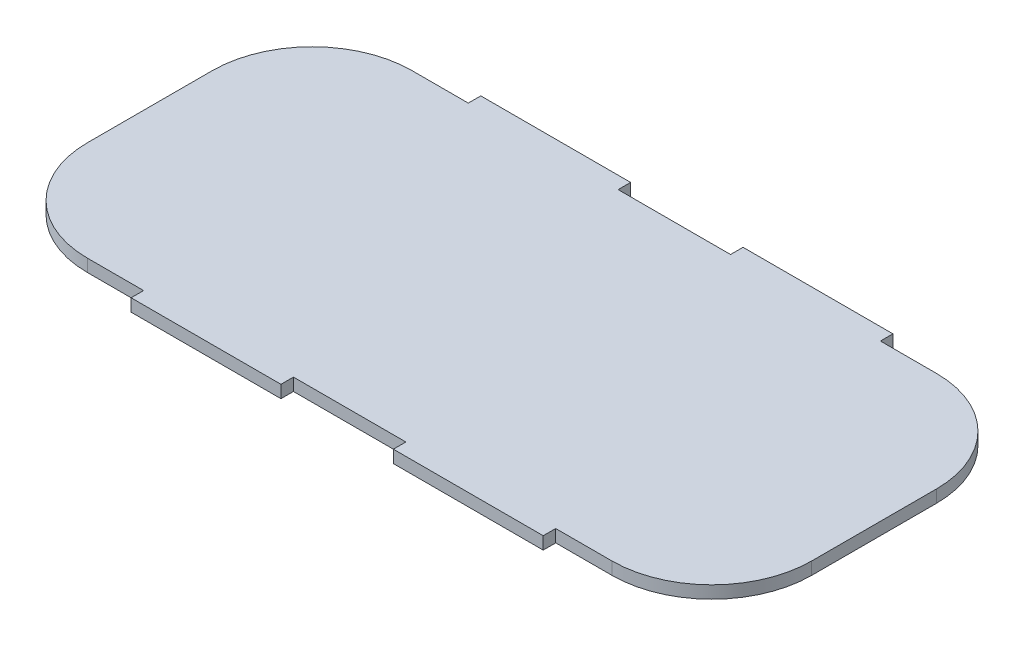
from build123d import *

# Parameters (mm, degrees)
BOSS_EXTRUDE2_DEPTH = 2.5


with BuildPart() as part:
    # Sketch1 → Boss-Extrude2 (new body)
    with BuildSketch(Plane(origin=(0, 0, 0), x_dir=(1, 0, 0), z_dir=(0, 1, 0))):
        with BuildLine():
            Line((-52.5, 32.5), (-41.25, 32.5))
            Line((-41.25, 32.5), (-41.25, 35))
            Line((-41.25, 35), (-11.25, 35))
            Line((-11.25, 35), (-11.25, 32.5))
            Line((-11.25, 32.5), (11.25, 32.5))
            Line((11.25, 32.5), (11.25, 35))
            Line((11.25, 35), (41.25, 35))
            Line((41.25, 35), (41.25, 32.5))
            Line((41.25, 32.5), (52.5, 32.5))
            ThreePointArc((52.5, 32.5), (66.642135624, 26.642135624), (72.5, 12.5))
            Line((72.5, 12.5), (72.5, -12.5))
            ThreePointArc((72.5, -12.5), (66.642135624, -26.642135624), (52.5, -32.5))
            Line((52.5, -32.5), (41.25, -32.5))
            Line((41.25, -32.5), (41.25, -35))
            Line((41.25, -35), (11.25, -35))
            Line((11.25, -35), (11.25, -32.5))
            Line((11.25, -32.5), (-11.25, -32.5))
            Line((-11.25, -32.5), (-11.25, -35))
            Line((-11.25, -35), (-41.25, -35))
            Line((-41.25, -35), (-41.25, -32.5))
            Line((-41.25, -32.5), (-52.5, -32.5))
            ThreePointArc((-52.5, -32.5), (-66.642135624, -26.642135624), (-72.5, -12.5))
            Line((-72.5, -12.5), (-72.5, 12.5))
            ThreePointArc((-72.5, 12.5), (-66.642135624, 26.642135624), (-52.5, 32.5))
        make_face()
    extrude(amount=BOSS_EXTRUDE2_DEPTH)


solid = part.part
